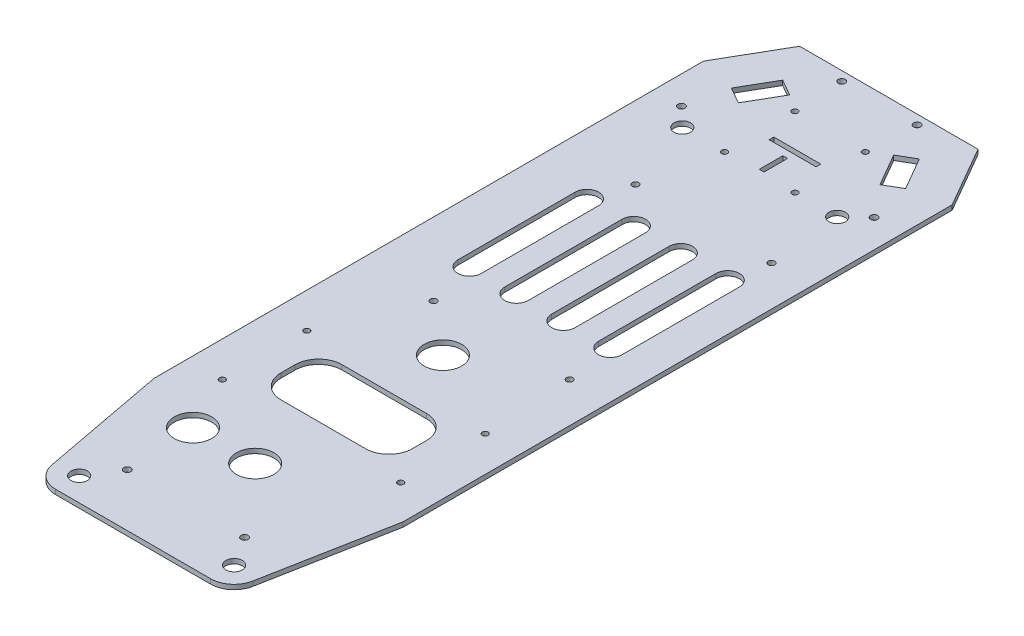
from build123d import *

# Parameters (mm, degrees)
ESQUISSE1_W              = 106
ESQUISSE1_H              = 332
ESQUISSE1_R              = 3.5
BOSS_EXTRU_1_DEPTH       = 2
ESQUISSE3_R              = 1.375
ENL_V_MAT_EXTRU_1_DEPTH  = 3
CHANFREIN1_SIZE          = 15
CHANFREIN1_SIZE2         = 25.980762114
ESQUISSE4_R              = 1.25
ESQUISSE4_W              = 56
ESQUISSE4_H              = 26
ENL_V_MAT_EXTRU_2_DEPTH  = 10
CONG_1_R                 = 10
ESQUISSE6_R              = 1.25
ESQUISSE6_W              = 20
ESQUISSE6_H              = 2
ESQUISSE6_W_2            = 2
ESQUISSE6_H_2            = 10
ENL_V_MAT_EXTRU_4_DEPTH  = 10
ESQUISSE7_R              = 8
ENL_V_MAT_EXTRU_5_DEPTH  = 10
ESQUISSE8_OUTSIDE_W      = 177.704
ESQUISSE8_OUTSIDE_H      = 403.704
ENL_V_MAT_EXTRU_6_DEPTH  = 10
ESQUISSE10_R             = 1.5
ENL_V_MAT_EXTRU_8_DEPTH  = 10
ESQUISSE11_R             = 1.5
ENL_V_MAT_EXTRU_9_DEPTH  = 10
ENL_V_MAT_EXTRU_10_DEPTH = 10
ESQUISSE13_R             = 8
ENL_V_MAT_EXTRU_11_DEPTH = 10


with BuildPart() as part:
    # Esquisse1 → Boss.-Extru.1 (new body)
    with BuildSketch(Plane(origin=(0, 0, 0), x_dir=(1, 0, 0), z_dir=(0, 1, 0))):
        with Locations((0, 17.5)):
            Rectangle(ESQUISSE1_W, ESQUISSE1_H)
        with Locations((-33, 128.5)):
            Circle(ESQUISSE1_R, mode=Mode.SUBTRACT)
        with Locations((-33, -128.5)):
            Circle(ESQUISSE1_R, mode=Mode.SUBTRACT)
        with Locations((33, 128.5)):
            Circle(ESQUISSE1_R, mode=Mode.SUBTRACT)
        with Locations((33, -128.5)):
            Circle(ESQUISSE1_R, mode=Mode.SUBTRACT)
    extrude(amount=BOSS_EXTRU_1_DEPTH)

    # Esquisse3 → Enlèv. mat.-Extru.1 (cut, through all)
    with BuildSketch(Plane(origin=(0, 2, 0), x_dir=(1, 0, 0), z_dir=(0, 1, 0))):
        with Locations((-22, 11.5)):
            Circle(ESQUISSE3_R)
        with Locations((-22, 97.5)):
            Circle(ESQUISSE3_R)
        with Locations((36, 97.5)):
            Circle(ESQUISSE3_R)
        with Locations((36, 11.5)):
            Circle(ESQUISSE3_R)
    extrude(amount=-ENL_V_MAT_EXTRU_1_DEPTH, mode=Mode.SUBTRACT)

    # Chanfrein1
    chanfrein1_edges = [part.edges().sort_by_distance(p)[0] for p in [
        (-53, 1, -183.5),
        (53, 1, -183.5),
    ]]
    chanfrein1_side = [part.faces().sort_by_distance(p)[0] for p in [
        (0, 1, -183.5),
    ]]
    chamfer(chanfrein1_edges, length=CHANFREIN1_SIZE, length2=CHANFREIN1_SIZE2, reference=chanfrein1_side[0])

    # Esquisse4 → Enlèv. mat.-Extru.2 (cut)
    with BuildSketch(Plane(origin=(0, 2, 0), x_dir=(1, 0, 0), z_dir=(0, 1, 0))):
        with Locations((38, -62.5)):
            Circle(ESQUISSE4_R)
        with Locations((38, -26.5)):
            Circle(ESQUISSE4_R)
        with Locations((-38, -62.5)):
            Circle(ESQUISSE4_R)
        with Locations((-38, -26.5)):
            Circle(ESQUISSE4_R)
        with Locations((0, -44.5)):
            Rectangle(ESQUISSE4_W, ESQUISSE4_H)
    extrude(amount=-ENL_V_MAT_EXTRU_2_DEPTH, mode=Mode.SUBTRACT)

    # Congé1
    cong_1_edges = [part.edges().sort_by_distance(p)[0] for p in [
        (-28, 1, 57.5),
        (-28, 1, 31.5),
        (28, 1, 31.5),
        (28, 1, 57.5),
    ]]
    fillet(cong_1_edges, radius=CONG_1_R)

    # Esquisse6 → Enlèv. mat.-Extru.4 (cut)
    with BuildSketch(Plane(origin=(0, 2, 0), x_dir=(1, 0, 0), z_dir=(0, 1, 0))):
        with Locations((-15, 128.5)):
            Circle(ESQUISSE6_R)
        with Locations((15, 128.5)):
            Circle(ESQUISSE6_R)
        with Locations((-15, 158.5)):
            Circle(ESQUISSE6_R)
        with Locations((15, 158.5)):
            Circle(ESQUISSE6_R)
        with Locations((0, 143.5)):
            Rectangle(ESQUISSE6_W, ESQUISSE6_H)
        with Locations((-0.179881847, 134.5)):
            Rectangle(ESQUISSE6_W_2, ESQUISSE6_H_2)
    extrude(amount=-ENL_V_MAT_EXTRU_4_DEPTH, mode=Mode.SUBTRACT)

    # Esquisse7 → Enlèv. mat.-Extru.5 (cut)
    with BuildSketch(Plane(origin=(0, 2, 0), x_dir=(1, 0, 0), z_dir=(0, 1, 0))):
        with Locations((0, -86.5)):
            Circle(ESQUISSE7_R)
        with Locations((-26.5, -86.5)):
            Circle(ESQUISSE7_R)
    extrude(amount=-ENL_V_MAT_EXTRU_5_DEPTH, mode=Mode.SUBTRACT)

    # Esquisse8 outside → Enlèv. mat.-Extru.6 (cut)
    with BuildSketch(Plane(origin=(0, 2, 0), x_dir=(1, 0, 0), z_dir=(0, 1, 0))):
        with Locations((0, 17.5)):
            Rectangle(ESQUISSE8_OUTSIDE_W, ESQUISSE8_OUTSIDE_H)
        with BuildLine():
            Line((38, 183.5), (-38, 183.5))
            Line((-38, 183.5), (-53, 157.519237886))
            Line((-53, 157.519237886), (-53, -76.5))
            Line((-53, -76.5), (-42.82620953, -130.356234435))
            ThreePointArc((-42.82620953, -130.356234435), (-39.381130607, -136.199426743), (-33, -138.5))
            Line((-33, -138.5), (33, -138.5))
            ThreePointArc((33, -138.5), (39.381130607, -136.199426743), (42.82620953, -130.356234435))
            Line((42.82620953, -130.356234435), (53, -76.5))
            Line((53, -76.5), (53, 157.519237886))
            Line((53, 157.519237886), (38, 183.5))
        make_face(mode=Mode.SUBTRACT)
    extrude(amount=-ENL_V_MAT_EXTRU_6_DEPTH, mode=Mode.SUBTRACT)

    # Esquisse10 → Enlèv. mat.-Extru.8 (cut)
    with BuildSketch(Plane.XZ):
        with Locations((16.063466521, -179.495190528)):
            Circle(ESQUISSE10_R)
        with Locations((41.063466521, -136.193920339)):
            Circle(ESQUISSE10_R)
        with Locations((-41.063466521, -136.193920339)):
            Circle(ESQUISSE10_R)
        with Locations((-16.063466521, -179.495190528)):
            Circle(ESQUISSE10_R)
        Polygon((32.563466521, -150.916352203), (30.18189666, -149.541352203), (26.186846942, -156.460981293), (22.18189666, -163.397758664), (24.563466521, -164.772758664), (29.11009989, -167.397758664), (37.11009989, -153.541352203), align=None)
        Polygon((-24.563466521, -164.772758664), (-22.18189666, -163.397758664), (-26.186846942, -156.460981293), (-30.18189666, -149.541352203), (-32.563466521, -150.916352203), (-37.11009989, -153.541352203), (-29.11009989, -167.397758664), align=None)
    extrude(amount=-ENL_V_MAT_EXTRU_8_DEPTH, mode=Mode.SUBTRACT)

    # Esquisse11 → Enlèv. mat.-Extru.9 (cut)
    with BuildSketch(Plane.XZ):
        with Locations((25, 116)):
            Circle(ESQUISSE11_R)
        with Locations((-25, 116)):
            Circle(ESQUISSE11_R)
    extrude(amount=-ENL_V_MAT_EXTRU_9_DEPTH, mode=Mode.SUBTRACT)

    # Esquisse12 → Enlèv. mat.-Extru.10 (cut)
    with BuildSketch(Plane.XZ):
        with BuildLine():
            Line((38, -31.843333074), (38, -81.843333074))
            ThreePointArc((38, -81.843333074), (33, -86.843333074), (28, -81.843333074))
            Line((28, -81.843333074), (28, -31.843333074))
            ThreePointArc((28, -31.843333074), (33, -26.843333074), (38, -31.843333074))
        make_face()
        with BuildLine():
            Line((18, -31.843333074), (18, -81.843333074))
            ThreePointArc((18, -81.843333074), (13, -86.843333074), (8, -81.843333074))
            Line((8, -81.843333074), (8, -31.843333074))
            ThreePointArc((8, -31.843333074), (13, -26.843333074), (18, -31.843333074))
        make_face()
        with BuildLine():
            Line((-2, -31.843333074), (-2, -81.843333074))
            ThreePointArc((-2, -81.843333074), (-7, -86.843333074), (-12, -81.843333074))
            Line((-12, -81.843333074), (-12, -31.843333074))
            ThreePointArc((-12, -31.843333074), (-7, -26.843333074), (-2, -31.843333074))
        make_face()
        with BuildLine():
            Line((-22, -31.843333074), (-22, -81.843333074))
            ThreePointArc((-22, -81.843333074), (-27, -86.843333074), (-32, -81.843333074))
            Line((-32, -81.843333074), (-32, -31.843333074))
            ThreePointArc((-32, -31.843333074), (-27, -26.843333074), (-22, -31.843333074))
        make_face()
    extrude(amount=-ENL_V_MAT_EXTRU_10_DEPTH, mode=Mode.SUBTRACT)

    # Esquisse13 → Enlèv. mat.-Extru.11 (cut)
    with BuildSketch(Plane.XZ):
        with Locations((0, 6.5)):
            Circle(ESQUISSE13_R)
    extrude(amount=-ENL_V_MAT_EXTRU_11_DEPTH, mode=Mode.SUBTRACT)


solid = part.part
